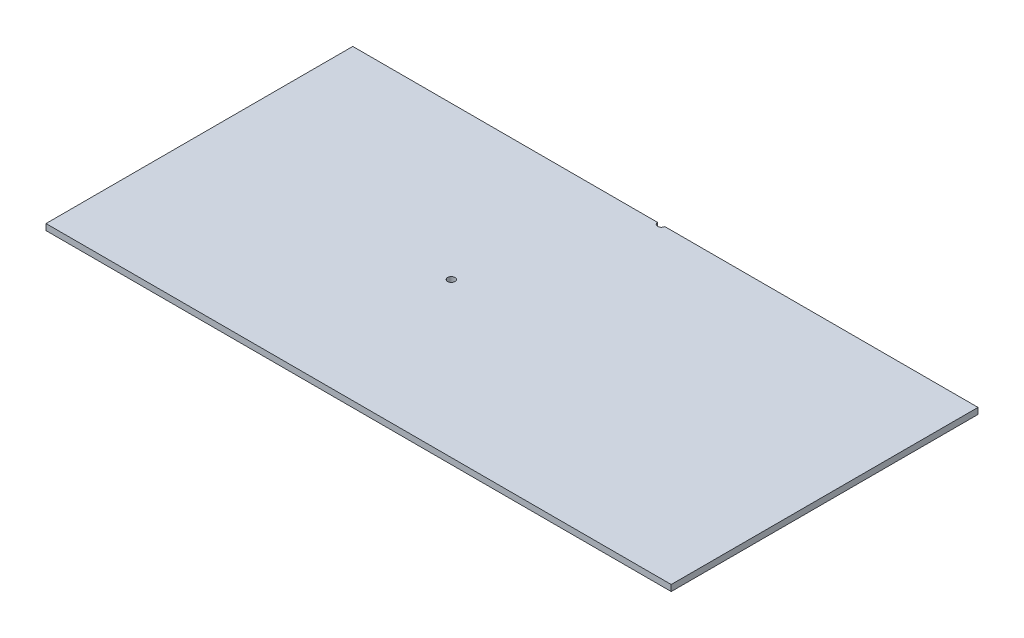
from build123d import *

# Parameters (mm, degrees)
SKETCH1_W                    = 258.4113781
SKETCH1_H                    = 126.795826844
BOSS_EXTRUDE1_DEPTH          = 2.54
F_3_0_3_DIAMETER_HOLE1_D     = 3
F_3_0_3_DIAMETER_HOLE1_DEPTH = 25.4
F_3_0_3_DIAMETER_HOLE1_TIP   = 0.901290929
F_3_0_3_DIAMETER_HOLE2_D     = 3
F_3_0_3_DIAMETER_HOLE2_DEPTH = 25.4
F_3_0_3_DIAMETER_HOLE2_TIP   = 0.901290929


with BuildPart() as part:
    # Sketch1 → Boss-Extrude1 (new body)
    with BuildSketch(Plane(origin=(0, 0, 0), x_dir=(1, 0, 0), z_dir=(0, 1, 0))):
        with Locations((11.493188983, -3.336732285)):
            Rectangle(SKETCH1_W, SKETCH1_H)
    extrude(amount=BOSS_EXTRUDE1_DEPTH)

    # Ø3.0 (3) Diameter Hole1
    with Locations(Plane(origin=(0, 2.54, 0), x_dir=(-1, 0, 0), z_dir=(0, 1, 0))):
        with Locations((13.924720288, 3.010786642)):
            Hole(F_3_0_3_DIAMETER_HOLE1_D / 2, depth=F_3_0_3_DIAMETER_HOLE1_DEPTH)
            with Locations((0, 0, -(F_3_0_3_DIAMETER_HOLE1_DEPTH + F_3_0_3_DIAMETER_HOLE1_TIP / 2))):  # 118° drill point
                Cone(0, F_3_0_3_DIAMETER_HOLE1_D / 2, F_3_0_3_DIAMETER_HOLE1_TIP, mode=Mode.SUBTRACT)

    # Ø3.0 (3) Diameter Hole2
    with Locations(Plane.XZ):
        with Locations((9.740449038, -60.135696584)):
            Hole(F_3_0_3_DIAMETER_HOLE2_D / 2, depth=F_3_0_3_DIAMETER_HOLE2_DEPTH)
            with Locations((0, 0, -(F_3_0_3_DIAMETER_HOLE2_DEPTH + F_3_0_3_DIAMETER_HOLE2_TIP / 2))):  # 118° drill point
                Cone(0, F_3_0_3_DIAMETER_HOLE2_D / 2, F_3_0_3_DIAMETER_HOLE2_TIP, mode=Mode.SUBTRACT)


solid = part.part
